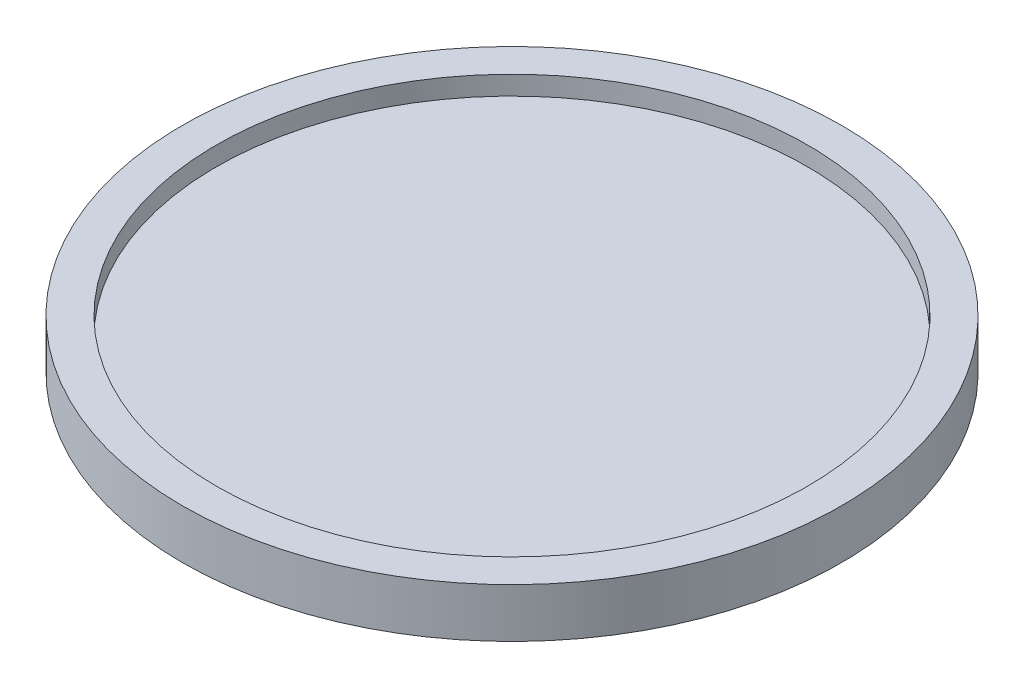
from build123d import *

# Parameters (mm, degrees)
CROQUIS1_R              = 43.5
SALIENTE_EXTRUIR1_DEPTH = 4
CROQUIS2_R              = 43.5
CROQUIS2_R_2            = 39.017907213
SALIENTE_EXTRUIR2_DEPTH = 2.5
CROQUIS3_R              = 38.31099811
CROQUIS3_R_2            = 33.604332007
SALIENTE_EXTRUIR3_DEPTH = 2.5


with BuildPart() as part:
    # Croquis1 → Saliente-Extruir1 (new body)
    with BuildSketch(Plane(origin=(0, 0, 0), x_dir=(1, 0, 0), z_dir=(0, 1, 0))):
        Circle(CROQUIS1_R)
    extrude(amount=SALIENTE_EXTRUIR1_DEPTH)

    # Croquis2 → Saliente-Extruir2 (add)
    with BuildSketch(Plane(origin=(0, 4, 0), x_dir=(1, 0, 0), z_dir=(0, 1, 0))):
        Circle(CROQUIS2_R)
        Circle(CROQUIS2_R_2, mode=Mode.SUBTRACT)
    extrude(amount=SALIENTE_EXTRUIR2_DEPTH)

    # Croquis3 → Saliente-Extruir3 (add)
    with BuildSketch(Plane.XZ):
        Circle(CROQUIS3_R)
        Circle(CROQUIS3_R_2, mode=Mode.SUBTRACT)
    extrude(amount=SALIENTE_EXTRUIR3_DEPTH)


solid = part.part
